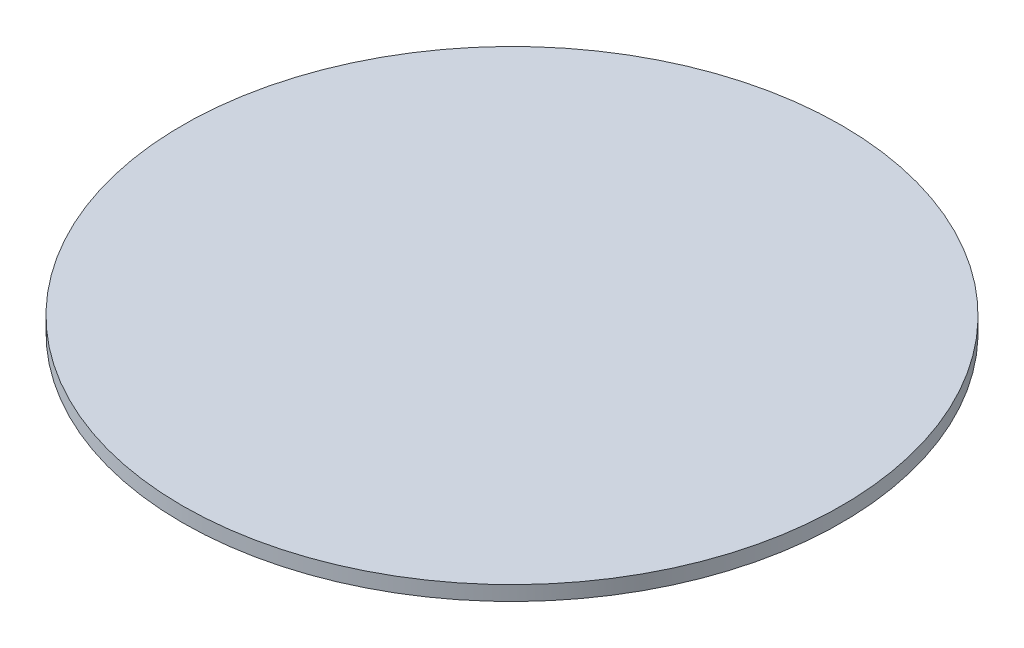
from build123d import *

# Parameters (mm, degrees)
SKETCH1_R           = 45
BOSS_EXTRUDE1_DEPTH = 2


with BuildPart() as part:
    # Sketch1 → Boss-Extrude1 (new body)
    with BuildSketch(Plane(origin=(0, 0, 0), x_dir=(1, 0, 0), z_dir=(0, 1, 0))):
        Circle(SKETCH1_R)
    extrude(amount=BOSS_EXTRUDE1_DEPTH)


solid = part.part
